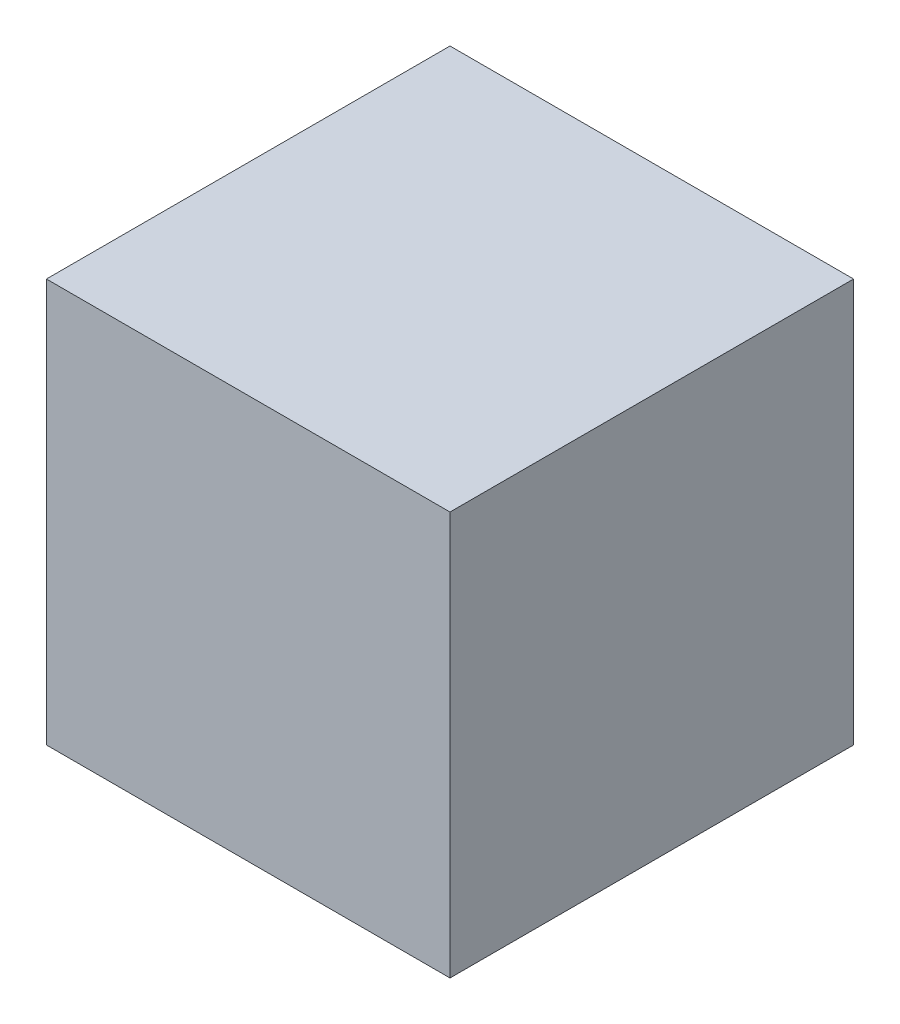
from build123d import *

# Parameters (mm, degrees)
SKETCH_1_W      = 48
SKETCH_1_H      = 48
EXTRUDE_1_DEPTH = 48


with BuildPart() as part:
    # 草圖1 → 填料-伸長1 (new body)
    with BuildSketch(Plane.XY):
        Rectangle(SKETCH_1_W, SKETCH_1_H)
    extrude(amount=EXTRUDE_1_DEPTH)


solid = part.part
